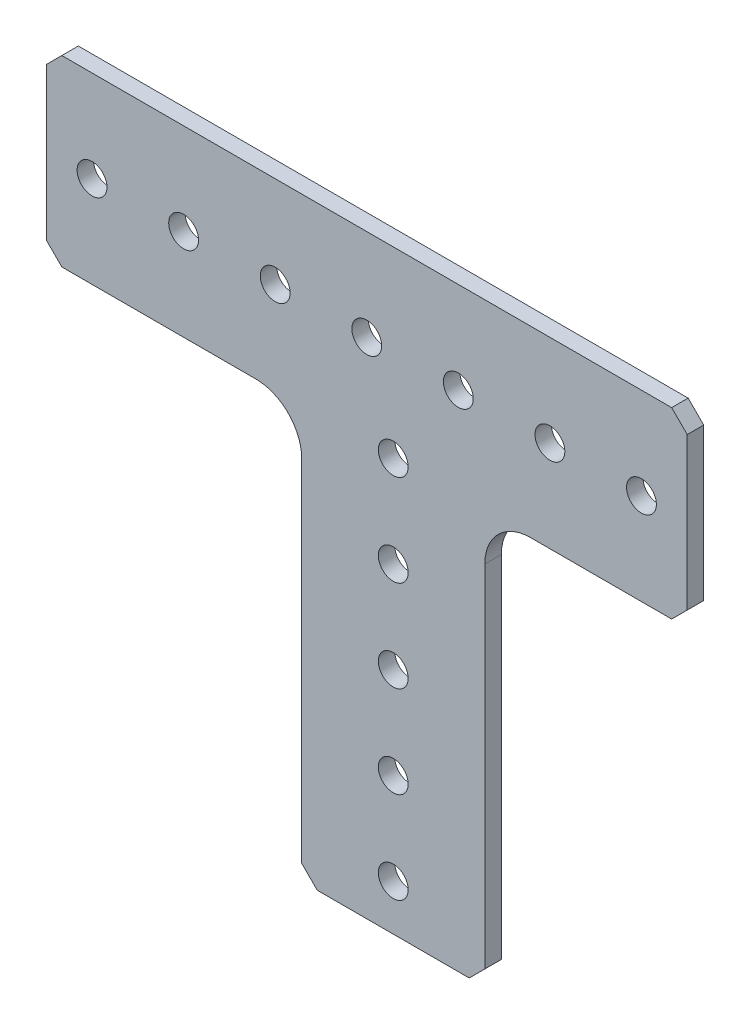
from build123d import *

# Parameters (mm, degrees)
SKETCH1_R           = 2.0701
BOSS_EXTRUDE1_DEPTH = 2.286


with BuildPart() as part:
    # Sketch1 → Boss-Extrude1 (new body)
    with BuildSketch(Plane.XY.offset(2.286)):
        with BuildLine():
            Line((16.372450872, -54.991), (16.372450872, -6.35))
            ThreePointArc((16.372450872, -6.35), (18.232322811, -1.859871939), (22.722450872, 0))
            Line((22.722450872, 0), (42.291, 0))
            Line((42.291, 0), (44.45, 2.159))
            Line((44.45, 2.159), (44.45, 23.241))
            Line((44.45, 23.241), (42.291, 25.4))
            Line((42.291, 25.4), (-42.291, 25.4))
            Line((-42.291, 25.4), (-44.45, 23.241))
            Line((-44.45, 23.241), (-44.45, 2.159))
            Line((-44.45, 2.159), (-42.291, 0))
            Line((-42.291, 0), (-15.377549128, 0))
            ThreePointArc((-15.377549128, 0), (-10.887421067, -1.859871939), (-9.027549128, -6.35))
            Line((-9.027549128, -6.35), (-9.027549128, -54.991))
            Line((-9.027549128, -54.991), (-6.868549128, -57.15))
            Line((-6.868549128, -57.15), (14.213450872, -57.15))
            Line((14.213450872, -57.15), (16.372450872, -54.991))
        make_face()
        with Locations((3.672450872, -38.1)):
            Circle(SKETCH1_R, mode=Mode.SUBTRACT)
        with Locations((3.672450872, -12.7)):
            Circle(SKETCH1_R, mode=Mode.SUBTRACT)
        with Locations((38.1, 12.7)):
            Circle(SKETCH1_R, mode=Mode.SUBTRACT)
        with Locations((12.7, 12.7)):
            Circle(SKETCH1_R, mode=Mode.SUBTRACT)
        with Locations((-12.7, 12.7)):
            Circle(SKETCH1_R, mode=Mode.SUBTRACT)
        with Locations((-38.1, 12.7)):
            Circle(SKETCH1_R, mode=Mode.SUBTRACT)
        with Locations((-25.4, 12.7)):
            Circle(SKETCH1_R, mode=Mode.SUBTRACT)
        with Locations((0, 12.7)):
            Circle(SKETCH1_R, mode=Mode.SUBTRACT)
        with Locations((25.4, 12.7)):
            Circle(SKETCH1_R, mode=Mode.SUBTRACT)
        with Locations((3.672450872, 0)):
            Circle(SKETCH1_R, mode=Mode.SUBTRACT)
        with Locations((3.672450872, -25.4)):
            Circle(SKETCH1_R, mode=Mode.SUBTRACT)
        with Locations((3.672450872, -50.8)):
            Circle(SKETCH1_R, mode=Mode.SUBTRACT)
    extrude(amount=-BOSS_EXTRUDE1_DEPTH)


solid = part.part
